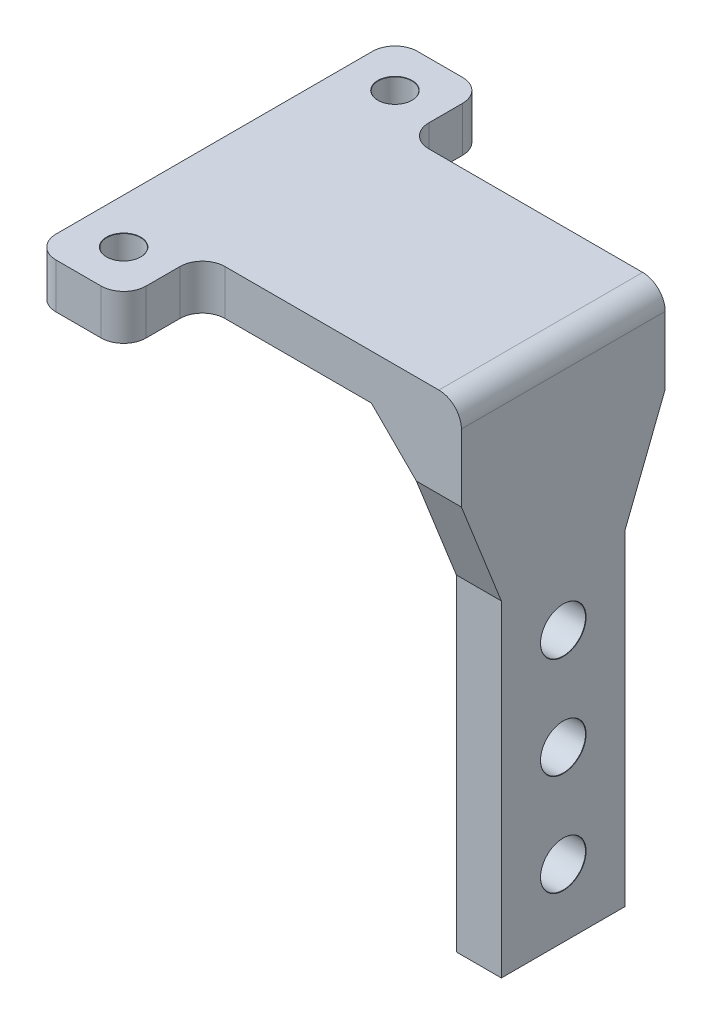
from build123d import *

# Parameters (mm, degrees)
BOSS_EXTRUDE1_DEPTH             = 4
FILLET1_R                       = 2
F_3_0MM_DOWEL_HOLE1_D           = 3
F_3_0MM_DOWEL_HOLE1_CSINK_D     = 3.05
F_3_0MM_DOWEL_HOLE1_CSINK_ANGLE = 90
SKETCH4_W                       = 4
SKETCH4_H                       = 18.1
BOSS_EXTRUDE2_DEPTH             = 42
CHAMFER1_SIZE                   = 4
FILLET2_R                       = 2
F_4_0MM_DOWEL_HOLE1_D           = 4
F_4_0MM_DOWEL_HOLE1_CSINK_D     = 4.05
F_4_0MM_DOWEL_HOLE1_CSINK_ANGLE = 90
CUT_EXTRUDE1_DEPTH              = 28
CUT_EXTRUDE1_DEPTH_BACK         = 5
CUT_EXTRUDE2_DEPTH              = 28
CUT_EXTRUDE2_DEPTH_BACK         = 5


with BuildPart() as part:
    # Sketch1 → Boss-Extrude1 (new body)
    with BuildSketch(Plane(origin=(0, 0, 0), x_dir=(1, 0, 0), z_dir=(0, 1, 0))):
        Polygon((0, 16.05), (0, -16.05), (8, -16.05), (8, -9.05), (31, -9.05), (31, 9.05), (8, 9.05), (8, 16.05), align=None)
    extrude(amount=BOSS_EXTRUDE1_DEPTH)

    # Fillet1
    fillet1_edges = [part.edges().sort_by_distance(p)[0] for p in [
        (8, 2, -16.05),
        (8, 2, -9.05),
        (8, 2, 9.05),
        (8, 2, 16.05),
        (0, 2, 16.05),
        (0, 2, -16.05),
    ]]
    fillet(fillet1_edges, radius=FILLET1_R)

    # Ø3.0mm Dowel Hole1 (through all)
    with Locations(Plane(origin=(0, 4, 0), x_dir=(1, 0, 0), z_dir=(0, 1, 0))):
        with Locations((4, 12.05), (4, -12.05)):
            CounterSinkHole(F_3_0MM_DOWEL_HOLE1_D / 2, F_3_0MM_DOWEL_HOLE1_CSINK_D / 2, counter_sink_angle=F_3_0MM_DOWEL_HOLE1_CSINK_ANGLE)

    # Sketch4 → Boss-Extrude2 (add)
    with BuildSketch(Plane(origin=(0, 0, 0), x_dir=(-1, 0, 0), z_dir=(0, -1, 0))):
        with Locations((-29, 0)):
            Rectangle(SKETCH4_W, SKETCH4_H)
    extrude(amount=BOSS_EXTRUDE2_DEPTH)

    # Chamfer1
    chamfer1_edges = [part.edges().sort_by_distance(p)[0] for p in [
        (27, 0, 0),
    ]]
    chamfer(chamfer1_edges, length=CHAMFER1_SIZE)

    # Fillet2
    fillet2_edges = [part.edges().sort_by_distance(p)[0] for p in [
        (31, 4, 0),
    ]]
    fillet(fillet2_edges, radius=FILLET2_R)

    # Ø4.0mm Dowel Hole1 (through all)
    with Locations(Plane(origin=(31, 0, 0), x_dir=(0, 0, -1), z_dir=(1, 0, 0))):
        with Locations((0, -36), (0, -27), (0, -18)):
            CounterSinkHole(F_4_0MM_DOWEL_HOLE1_D / 2, F_4_0MM_DOWEL_HOLE1_CSINK_D / 2, counter_sink_angle=F_4_0MM_DOWEL_HOLE1_CSINK_ANGLE)

    # Sketch11 → Cut-Extrude1 (cut, two sides)
    with BuildSketch(Plane.ZY.offset(-27)) as cut_extrude1_sk:
        Polygon((-9.05, -4), (-5.5, -13), (-5.5, -42), (-9.05, -42), align=None)
    extrude(amount=CUT_EXTRUDE1_DEPTH, mode=Mode.SUBTRACT)
    extrude(cut_extrude1_sk.sketch, amount=-CUT_EXTRUDE1_DEPTH_BACK, mode=Mode.SUBTRACT)

    # Sketch12 → Cut-Extrude2 (cut, two sides)
    with BuildSketch(Plane.ZY.offset(-27)) as cut_extrude2_sk:
        Polygon((9.05, -4), (5.5, -13), (5.5, -42), (9.05, -42), align=None)
    extrude(amount=CUT_EXTRUDE2_DEPTH, mode=Mode.SUBTRACT)
    extrude(cut_extrude2_sk.sketch, amount=-CUT_EXTRUDE2_DEPTH_BACK, mode=Mode.SUBTRACT)


solid = part.part
